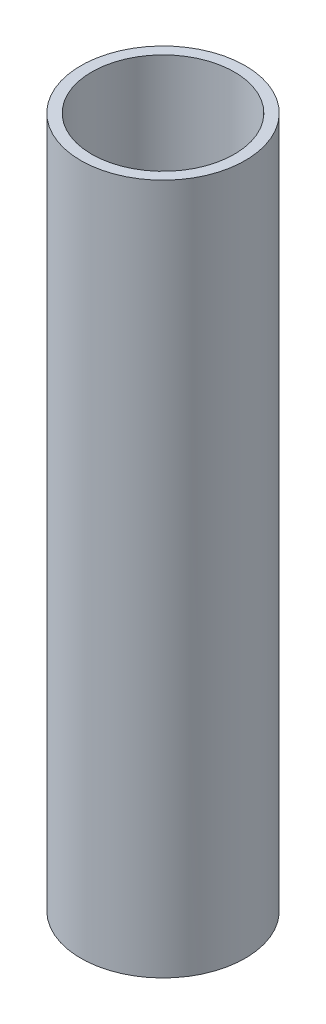
from build123d import *

# Parameters (mm, degrees)
SKETCH1_R           = 12.85
SKETCH1_R_2         = 11.15
BOSS_EXTRUDE1_DEPTH = 102
SKETCH2_R           = 12.85
BOSS_EXTRUDE2_DEPTH = 6


with BuildPart() as part:
    # Sketch1 → Boss-Extrude1 (new body)
    with BuildSketch(Plane(origin=(0, 0, 0), x_dir=(1, 0, 0), z_dir=(0, 1, 0))):
        Circle(SKETCH1_R)
        Circle(SKETCH1_R_2, mode=Mode.SUBTRACT)
    extrude(amount=BOSS_EXTRUDE1_DEPTH)

    # Sketch2 → Boss-Extrude2 (add)
    with BuildSketch(Plane.XZ):
        Circle(SKETCH2_R)
    extrude(amount=BOSS_EXTRUDE2_DEPTH)


solid = part.part
